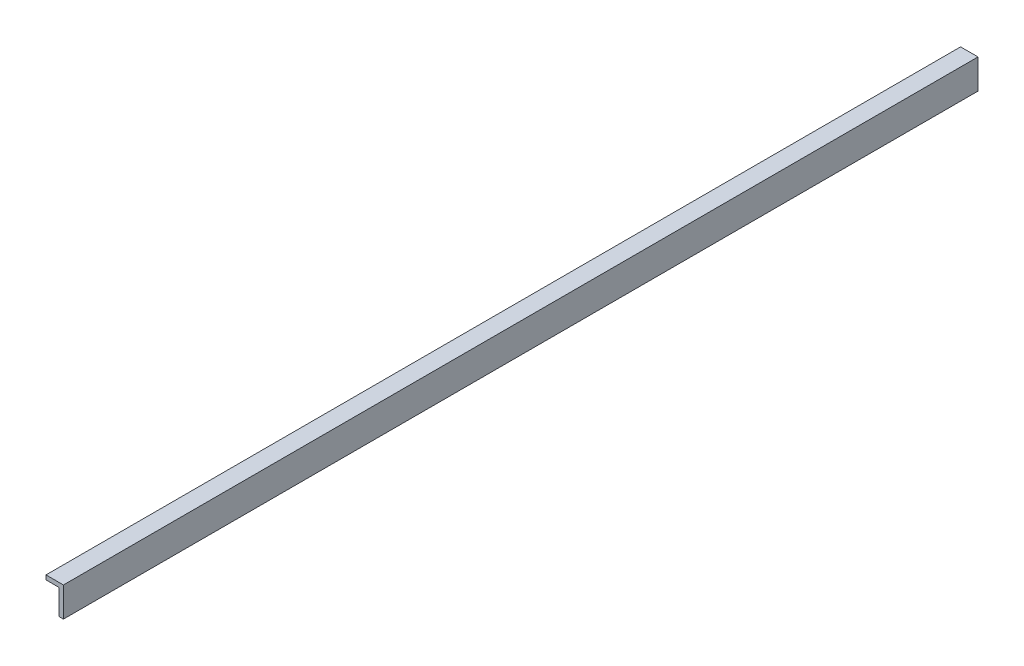
from build123d import *

# Parameters (mm, degrees)
CROQUIS1_W              = 15
CROQUIS1_H              = 5
SALIENTE_EXTRUIR1_DEPTH = 1050


with BuildPart() as part:
    # Croquis1 → Saliente-Extruir1 (new body)
    with BuildSketch(Plane.XY):
        Polygon((-5, 0), (0, 0), (0, 34), (-5, 34), (-5, 29), align=None)
        with Locations((-12.5, 31.5)):
            Rectangle(CROQUIS1_W, CROQUIS1_H)
    extrude(amount=-SALIENTE_EXTRUIR1_DEPTH)


solid = part.part
